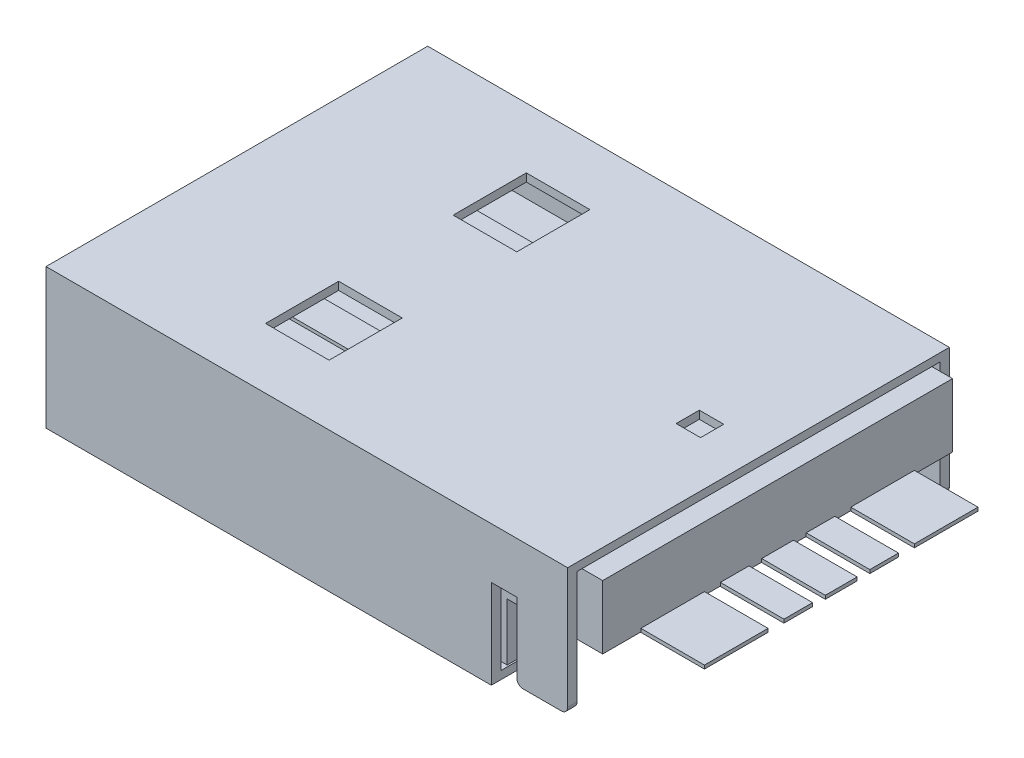
from build123d import *

# Parameters (mm, degrees)
EXTRUDE_1_DEPTH          = 11
SKETCH_3_W               = 4
SKETCH_3_H               = 1
SKETCH_3_H_2             = 2
EXTRUDE_2_DEPTH          = 0.1
SKETCH_5_W               = 4.70699789
SKETCH_5_H               = 1.4
CUT_EXTRUDE_2_DEPTH      = 2.8
CUT_EXTRUDE_2_DEPTH_BACK = 3
EXTRUDE_3_DEPTH          = 0.5
FILLET_1_R               = 0.6
SKETCH_6_W               = 5
SKETCH_6_H               = 0.9
SKETCH_6_H_2             = 2
SKETCH_6_H_3             = 1
EXTRUDE_4_DEPTH          = 0.01
EXTRUDE_4_DEPTH_BACK     = 0.1
FILLET_2_R               = 0.4
SKETCH_8_W               = 12
SKETCH_8_H               = 4.4
SKETCH_8_W_2             = 11.4
SKETCH_8_H_2             = 3.9
EXTRUDE_5_DEPTH          = 16.4
SKETCH_9_W               = 2
SKETCH_9_H               = 2.3
SKETCH_9_W_2             = 0.767462698
SKETCH_9_H_2             = 0.729858924
CUT_EXTRUDE_5_DEPTH      = 0.25
SKETCH_12_W              = 2
SKETCH_12_H              = 2.3
CUT_EXTRUDE_6_DEPTH      = 0.25
CUT_EXTRUDE_7_DEPTH      = 1
CUT_EXTRUDE_7_DEPTH_BACK = 13
FILLET_4_R               = 0.2


with BuildPart() as part:
    # 草图2 → 凸台-拉伸1 (new body)
    with BuildSketch(Plane.XY):
        Polygon((0, 0), (-14, 0), (-14, 2), (-5, 2), (-5, 3.8), (3, 3.8), (3, 1.8), (0, 1.8), align=None)
    extrude(amount=EXTRUDE_1_DEPTH)

    # 草图3 → 凸台-拉伸2 (add)
    with BuildSketch(Plane(origin=(0, 2, 0), x_dir=(1, 0, 0), z_dir=(0, 1, 0))):
        with Locations((-11, -6.5)):
            Rectangle(SKETCH_3_W, SKETCH_3_H)
        with Locations((-11, -8.8)):
            Rectangle(SKETCH_3_W, SKETCH_3_H_2)
        with Locations((-11, -4.5)):
            Rectangle(SKETCH_3_W, SKETCH_3_H)
        with Locations((-11, -2.2)):
            Rectangle(SKETCH_3_W, SKETCH_3_H_2)
    extrude(amount=EXTRUDE_2_DEPTH)

    # 草图5 → 切除-拉伸2 (cut, two sides)
    with BuildSketch(Plane(origin=(0, 2, 0), x_dir=(1, 0, 0), z_dir=(0, 1, 0))) as cut_extrude_2_sk:
        with Locations((-6.40593933, -5.5)):
            Rectangle(SKETCH_5_W, SKETCH_5_H)
    extrude(amount=CUT_EXTRUDE_2_DEPTH, mode=Mode.SUBTRACT)
    extrude(cut_extrude_2_sk.sketch, amount=-CUT_EXTRUDE_2_DEPTH_BACK, mode=Mode.SUBTRACT)

    # 草图4 → 凸台-拉伸3 (add, symmetric)
    with BuildSketch(Plane.XY.offset(5.5)):
        Polygon((-8.486379068, 0.97747076), (-7.544801814, 2.552308695), (-6.918443353, 2.552308695), (-4.052440385, 0.838758912), (-4.052440385, 0.585620875), (-6.92380134, 2.302374137), (-7.456665732, 2.302374137), (-8.317726091, 0.862204981), align=None)
    extrude(amount=EXTRUDE_3_DEPTH, both=True)

    # 圆角1
    fillet_1_edges = [part.edges().sort_by_distance(p)[0] for p in [
        (-6.918443353, 2.552308695, 5.5),
        (-7.544801814, 2.552308695, 5.5),
        (-7.456665732, 2.302374137, 5.5),
        (-6.92380134, 2.302374137, 5.5),
    ]]
    fillet(fillet_1_edges, radius=FILLET_1_R)

    # 草图6 → 凸台-拉伸4 (add, two sides)
    with BuildSketch(Plane.XZ.offset(-1.8)) as extrude_4_sk:
        with Locations((2.5, 4.15)):
            Rectangle(SKETCH_6_W, SKETCH_6_H)
        with Locations((2.5, 8.8)):
            Rectangle(SKETCH_6_W, SKETCH_6_H_2)
        with Locations((2.5, 6.85)):
            Rectangle(SKETCH_6_W, SKETCH_6_H)
        with Locations((2.5, 2.2)):
            Rectangle(SKETCH_6_W, SKETCH_6_H_2)
        with Locations((2.5, 5.5)):
            Rectangle(SKETCH_6_W, SKETCH_6_H_3)
    extrude(amount=EXTRUDE_4_DEPTH)
    extrude(extrude_4_sk.sketch, amount=-EXTRUDE_4_DEPTH_BACK)

    # 圆角2
    fillet_2_edges = [part.edges().sort_by_distance(p)[0] for p in [
        (-14, 2, 5.5),
    ]]
    fillet(fillet_2_edges, radius=FILLET_2_R)


with BuildPart() as body_2:
    # 草图8 → 凸台-拉伸5 (new body)
    with BuildSketch(Plane.ZY.offset(14)):
        with Locations((5.5, 1.9)):
            Rectangle(SKETCH_8_W, SKETCH_8_H)
        with Locations((5.5, 1.9)):
            Rectangle(SKETCH_8_W_2, SKETCH_8_H_2, mode=Mode.SUBTRACT)
    extrude(amount=-EXTRUDE_5_DEPTH)

    # 草图9 → 切除-拉伸5 (cut)
    with BuildSketch(Plane(origin=(0, 4.1, 0), x_dir=(1, 0, 0), z_dir=(0, 1, 0))):
        with Locations((-8, -2.55)):
            Rectangle(SKETCH_9_W, SKETCH_9_H)
        with Locations((-8, -8.45)):
            Rectangle(SKETCH_9_W, SKETCH_9_H)
        with Locations((0.563339888, -5.505397464)):
            Rectangle(SKETCH_9_W_2, SKETCH_9_H_2)
    extrude(amount=-CUT_EXTRUDE_5_DEPTH, mode=Mode.SUBTRACT)

    # 草图12 → 切除-拉伸6 (cut)
    with BuildSketch(Plane.XZ.offset(0.3)):
        with Locations((-8, 8.45)):
            Rectangle(SKETCH_12_W, SKETCH_12_H)
        with Locations((-8, 2.55)):
            Rectangle(SKETCH_12_W, SKETCH_12_H)
    extrude(amount=-CUT_EXTRUDE_6_DEPTH, mode=Mode.SUBTRACT)

    # 草图13 → 切除-拉伸7 (cut, two sides)
    with BuildSketch(Plane.XY.offset(11.5)) as cut_extrude_7_sk:
        Polygon((2.4, 0.1), (0.8, 0.1), (0.8, 2.5), (0, 2.5), (0, -0.781778745), (2.4, -0.781778745), align=None)
    extrude(amount=CUT_EXTRUDE_7_DEPTH, mode=Mode.SUBTRACT)
    extrude(cut_extrude_7_sk.sketch, amount=-CUT_EXTRUDE_7_DEPTH_BACK, mode=Mode.SUBTRACT)

    # 圆角4
    fillet_4_edges = [body_2.edges().sort_by_distance(p)[0] for p in [
        (0.8, 0.1, -0.35),
        (0.8, 0.1, 11.35),
        (2.4, 0.1, -0.35),
        (2.4, 0.1, 11.35),
    ]]
    fillet(fillet_4_edges, radius=FILLET_4_R)


solid = Compound([part.part, body_2.part])
